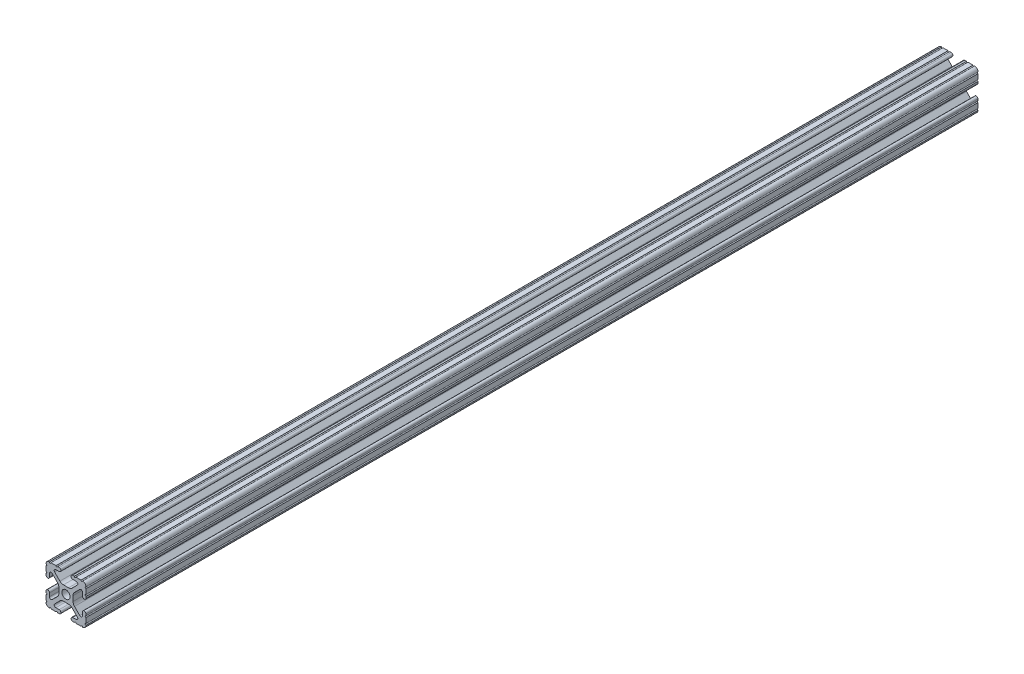
from build123d import *

# Parameters (mm, degrees)
SKETCH1_R           = 2.6035
BOSS_EXTRUDE1_DEPTH = 566.7375


with BuildPart() as part:
    # Sketch1 → Boss-Extrude1 (new body)
    with BuildSketch(Plane.XY):
        with BuildLine():
            Line((-12.7, -6.3330836), (-12.7, -9.5504))
            ThreePointArc((-12.7, -9.5504), (-12.192000006, -10.058323491), (-12.699846982, -10.566399977))
            ThreePointArc((-12.699846982, -10.566399977), (-12.082522516, -12.082522516), (-10.566399977, -12.699846982))
            ThreePointArc((-10.566399977, -12.699846982), (-10.058323491, -12.192000006), (-9.5504, -12.7))
            Line((-9.5504, -12.7), (-6.3330836, -12.7))
            ThreePointArc((-6.3330836, -12.7), (-5.8250836, -12.192), (-5.3170836, -12.7))
            Line((-5.3170836, -12.7), (-4.343399971, -12.7))
            ThreePointArc((-4.343399971, -12.7), (-3.238499971, -11.5951), (-4.343399971, -10.4902))
            Line((-4.343399971, -10.4902), (-6.474794456, -10.4902))
            ThreePointArc((-6.474794456, -10.4902), (-7.413456061, -9.863006367), (-7.193214945, -8.75577951))
            Line((-7.193214945, -8.75577951), (-3.863171405, -5.42573597))
            ThreePointArc((-3.863171405, -5.42573597), (-2.833127272, -4.737482484), (-1.618107374, -4.4958))
            Line((-1.618107374, -4.4958), (1.618107374, -4.4958))
            ThreePointArc((1.618107374, -4.4958), (2.833127272, -4.737482484), (3.863171405, -5.42573597))
            Line((3.863171405, -5.42573597), (7.193214945, -8.75577951))
            ThreePointArc((7.193214945, -8.75577951), (7.413456061, -9.863006367), (6.474794456, -10.4902))
            Line((6.474794456, -10.4902), (4.3434, -10.4902))
            ThreePointArc((4.3434, -10.4902), (3.2385, -11.5951), (4.3434, -12.7))
            Line((4.3434, -12.7), (5.3170836, -12.7))
            ThreePointArc((5.3170836, -12.7), (5.8250836, -12.192), (6.3330836, -12.7))
            Line((6.3330836, -12.7), (9.5504, -12.7))
            ThreePointArc((9.5504, -12.7), (10.058323491, -12.192000006), (10.566399977, -12.699846982))
            ThreePointArc((10.566399977, -12.699846982), (12.082522516, -12.082522516), (12.699846982, -10.566399977))
            ThreePointArc((12.699846982, -10.566399977), (12.192000006, -10.058323491), (12.7, -9.5504))
            Line((12.7, -9.5504), (12.7, -6.3330836))
            ThreePointArc((12.7, -6.3330836), (12.192, -5.8250836), (12.7, -5.3170836))
            Line((12.7, -5.3170836), (12.7, -4.343399971))
            ThreePointArc((12.7, -4.343399971), (11.5951, -3.238499971), (10.4902, -4.343399971))
            Line((10.4902, -4.343399971), (10.4902, -6.474794456))
            ThreePointArc((10.4902, -6.474794456), (9.863006367, -7.413456061), (8.75577951, -7.193214945))
            Line((8.75577951, -7.193214945), (5.42573597, -3.863171405))
            ThreePointArc((5.42573597, -3.863171405), (4.737482484, -2.833127272), (4.4958, -1.618107374))
            Line((4.4958, -1.618107374), (4.4958, 1.618107374))
            ThreePointArc((4.4958, 1.618107374), (4.737482484, 2.833127272), (5.42573597, 3.863171405))
            Line((5.42573597, 3.863171405), (8.75577951, 7.193214945))
            ThreePointArc((8.75577951, 7.193214945), (9.863006367, 7.413456061), (10.4902, 6.474794456))
            Line((10.4902, 6.474794456), (10.4902, 4.3434))
            ThreePointArc((10.4902, 4.3434), (11.5951, 3.2385), (12.7, 4.3434))
            Line((12.7, 4.3434), (12.7, 5.3170836))
            ThreePointArc((12.7, 5.3170836), (12.192, 5.8250836), (12.7, 6.3330836))
            Line((12.7, 6.3330836), (12.7, 9.5504))
            ThreePointArc((12.7, 9.5504), (12.192000006, 10.058323491), (12.699846982, 10.566399977))
            ThreePointArc((12.699846982, 10.566399977), (12.082522516, 12.082522516), (10.566399977, 12.699846982))
            ThreePointArc((10.566399977, 12.699846982), (10.058323491, 12.192000006), (9.5504, 12.7))
            Line((9.5504, 12.7), (6.3330836, 12.7))
            ThreePointArc((6.3330836, 12.7), (5.8250836, 12.192), (5.3170836, 12.7))
            Line((5.3170836, 12.7), (4.343399971, 12.7))
            ThreePointArc((4.343399971, 12.7), (3.238499971, 11.5951), (4.343399971, 10.4902))
            Line((4.343399971, 10.4902), (6.474794456, 10.4902))
            ThreePointArc((6.474794456, 10.4902), (7.413456061, 9.863006367), (7.193214945, 8.75577951))
            Line((7.193214945, 8.75577951), (3.863171405, 5.42573597))
            ThreePointArc((3.863171405, 5.42573597), (2.833127272, 4.737482484), (1.618107374, 4.4958))
            Line((1.618107374, 4.4958), (-1.618107374, 4.4958))
            ThreePointArc((-1.618107374, 4.4958), (-2.833127272, 4.737482484), (-3.863171405, 5.42573597))
            Line((-3.863171405, 5.42573597), (-7.193214945, 8.75577951))
            ThreePointArc((-7.193214945, 8.75577951), (-7.413456061, 9.863006367), (-6.474794456, 10.4902))
            Line((-6.474794456, 10.4902), (-4.3434, 10.4902))
            ThreePointArc((-4.3434, 10.4902), (-3.2385, 11.5951), (-4.3434, 12.7))
            Line((-4.3434, 12.7), (-5.3170836, 12.7))
            ThreePointArc((-5.3170836, 12.7), (-5.8250836, 12.192), (-6.3330836, 12.7))
            Line((-6.3330836, 12.7), (-9.5504, 12.7))
            ThreePointArc((-9.5504, 12.7), (-10.058323491, 12.192000006), (-10.566399977, 12.699846982))
            ThreePointArc((-10.566399977, 12.699846982), (-12.082522516, 12.082522516), (-12.699846982, 10.566399977))
            ThreePointArc((-12.699846982, 10.566399977), (-12.192000006, 10.058323491), (-12.7, 9.5504))
            Line((-12.7, 9.5504), (-12.7, 6.3330836))
            ThreePointArc((-12.7, 6.3330836), (-12.192, 5.8250836), (-12.7, 5.3170836))
            Line((-12.7, 5.3170836), (-12.7, 4.343399971))
            ThreePointArc((-12.7, 4.343399971), (-11.5951, 3.238499971), (-10.4902, 4.343399971))
            Line((-10.4902, 4.343399971), (-10.4902, 6.474794456))
            ThreePointArc((-10.4902, 6.474794456), (-9.863006367, 7.413456061), (-8.75577951, 7.193214945))
            Line((-8.75577951, 7.193214945), (-5.42573597, 3.863171405))
            ThreePointArc((-5.42573597, 3.863171405), (-4.737482484, 2.833127272), (-4.4958, 1.618107374))
            Line((-4.4958, 1.618107374), (-4.4958, -1.618107374))
            ThreePointArc((-4.4958, -1.618107374), (-4.737482484, -2.833127272), (-5.42573597, -3.863171405))
            Line((-5.42573597, -3.863171405), (-8.75577951, -7.193214945))
            ThreePointArc((-8.75577951, -7.193214945), (-9.863006367, -7.413456061), (-10.4902, -6.474794456))
            Line((-10.4902, -6.474794456), (-10.4902, -4.3434))
            ThreePointArc((-10.4902, -4.3434), (-11.5951, -3.2385), (-12.7, -4.3434))
            Line((-12.7, -4.3434), (-12.7, -5.3170836))
            ThreePointArc((-12.7, -5.3170836), (-12.192, -5.8250836), (-12.7, -6.3330836))
        make_face()
        Circle(SKETCH1_R, mode=Mode.SUBTRACT)
    extrude(amount=-BOSS_EXTRUDE1_DEPTH)


solid = part.part
